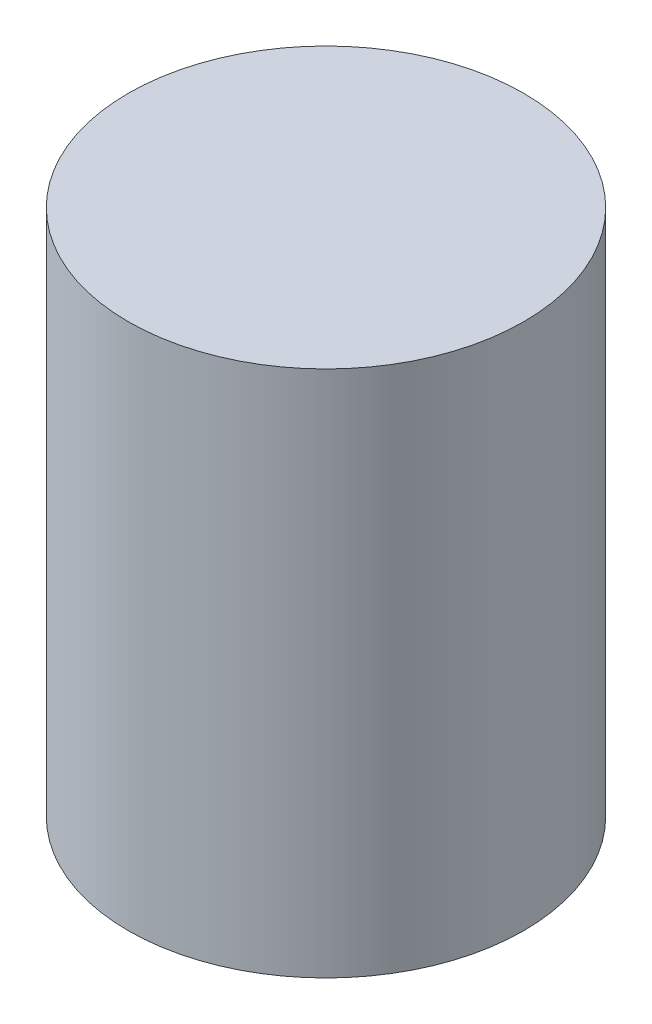
from build123d import *

# Parameters (mm, degrees)
SKETCH2_R           = 2.38125
BOSS_EXTRUDE1_DEPTH = 6.35


with BuildPart() as part:
    # Sketch2 → Boss-Extrude1 (new body)
    with BuildSketch(Plane(origin=(0, 0, 0), x_dir=(1, 0, 0), z_dir=(0, 1, 0))):
        Circle(SKETCH2_R)
    extrude(amount=BOSS_EXTRUDE1_DEPTH)


solid = part.part
